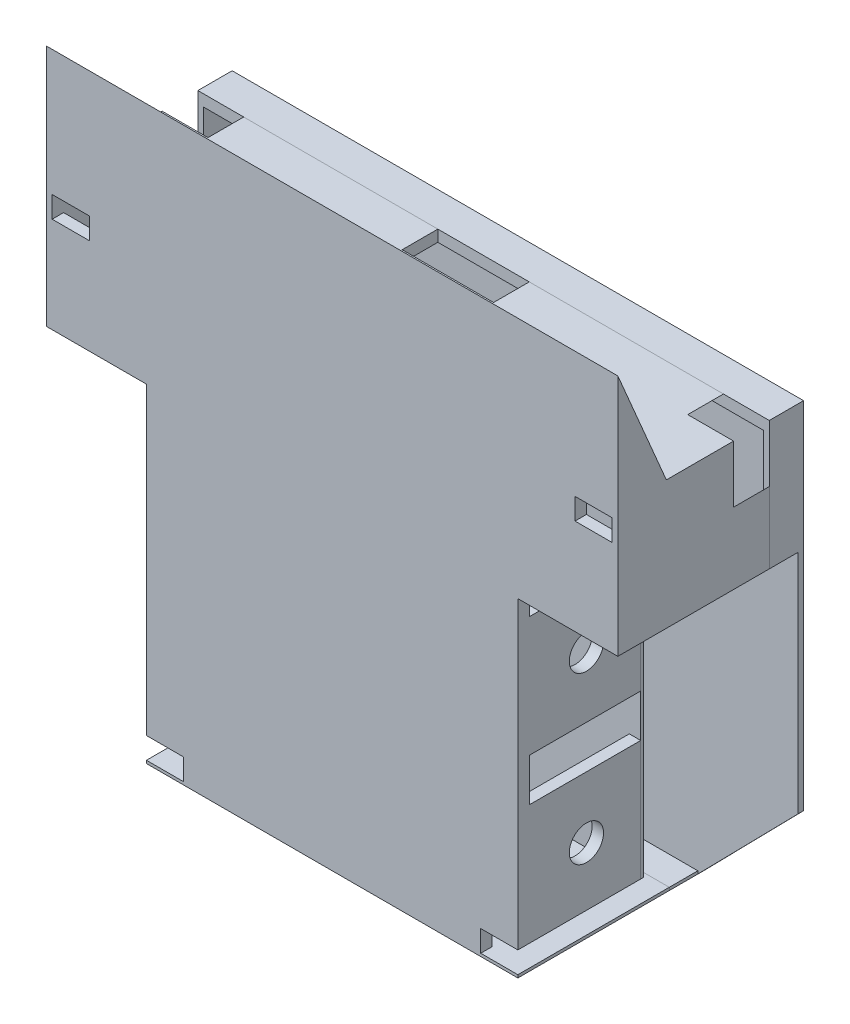
from build123d import *

# Parameters (mm, degrees)
BOSS_EXTRUDE1_DEPTH    = 4
BOSS_EXTRUDE2_DEPTH    = 53
BOSS_EXTRUDE4_DEPTH    = 200
SKETCH5_W              = 25.514718625
SKETCH5_H              = 12.5
CUT_EXTRUDE1_DEPTH     = 20
SKETCH6_W              = 12.5
SKETCH6_H              = 25.514718626
CUT_EXTRUDE2_DEPTH     = 20
BOSS_EXTRUDE5_DEPTH    = 4
SKETCH9_W              = 4
SKETCH9_H              = 99
BOSS_EXTRUDE6_DEPTH    = 39
SKETCH10_W             = 39
SKETCH10_H             = 15
CUT_EXTRUDE5_DEPTH     = 137
SKETCH12_W             = 35
SKETCH12_H             = 53
CUT_EXTRUDE6_DEPTH     = 8
SKETCH13_R             = 6
CUT_EXTRUDE7_DEPTH     = 135
SKETCH15_W             = 129.449663631
SKETCH15_H             = 99
BOSS_EXTRUDE7_DEPTH    = 1
SPLIT1_SURFACE_1_BACK  = 288.766
SPLIT1_SURFACE_1_DEPTH = 577.532
SPLIT1_SURFACE_2_BACK  = 288.766
SPLIT1_SURFACE_2_DEPTH = 577.532
SKETCH17_W             = 13
SKETCH17_H             = 7.5
CUT_EXTRUDE8_DEPTH     = 10
SKETCH21_W             = 130
SKETCH21_H             = 1
BOSS_EXTRUDE10_DEPTH   = 10
SKETCH23_W             = 32
SKETCH23_H             = 12.5
CUT_EXTRUDE9_DEPTH     = 10
BOSS_EXTRUDE14_DEPTH   = 2
SPLIT2_SURFACE_3_BACK  = 291.215
SPLIT2_SURFACE_3_DEPTH = 582.43
SPLIT2_SURFACE_4_BACK  = 291.215
SPLIT2_SURFACE_4_DEPTH = 582.43


with BuildPart() as part:
    # Sketch1 → Boss-Extrude1 (new body)
    with BuildSketch(Plane.XY):
        Polygon((175.95836944, 160), (24.04163056, 160), (0, 135.95836944), (0, 115), (35, 115), (35, 60), (35, 55), (35, 0), (165, 0), (165, 55), (165, 60), (165, 115), (200, 115), (200, 135.95836944), align=None)
    extrude(amount=BOSS_EXTRUDE1_DEPTH)

    # Sketch3 → Boss-Extrude2 (add)
    with BuildSketch(Plane.XY.offset(4)):
        Polygon((0, 0), (200, 0), (200, 1), (199, 1), (1, 1), (0, 1), align=None)
        Polygon((0, 160), (200, 160), (200, 115), (198, 115), (198, 156), (2, 156), (2, 115), (0, 115), align=None)
    extrude(amount=-BOSS_EXTRUDE2_DEPTH)

    # Sketch4 → Boss-Extrude4 (add)
    with BuildSketch(Plane(origin=(200, 0, 0), x_dir=(0, 0, -1), z_dir=(1, 0, 0))):
        Polygon((-4, 160), (-4, 200), (12.978992648, 160), align=None)
    extrude(amount=-BOSS_EXTRUDE4_DEPTH)

    # Sketch5 → Cut-Extrude1 (cut)
    with BuildSketch(Plane(origin=(-67.97918472, 67.97918472, 0), x_dir=(0.7071067811865505, 0.7071067811865447, 0), z_dir=(-0.7071067811865447, 0.7071067811865505, 0))):
        with Locations((111.722871428, 42.75)):
            Rectangle(SKETCH5_W, SKETCH5_H)
    extrude(amount=CUT_EXTRUDE1_DEPTH, mode=Mode.SUBTRACT)

    # Sketch6 → Cut-Extrude2 (cut)
    with BuildSketch(Plane(origin=(167.97918472, 167.97918472, 0), x_dir=(0, 0, -1), z_dir=(0.7071067811865493, 0.7071067811865458, 0))):
        with Locations((42.75, -29.69848481)):
            Rectangle(SKETCH6_W, SKETCH6_H)
    extrude(amount=CUT_EXTRUDE2_DEPTH, mode=Mode.SUBTRACT)

    # Sketch8 → Boss-Extrude5 (add)
    with BuildSketch(Plane.XY.offset(4)):
        Polygon((20.04163056, 156), (2, 156), (2, 137.95836944), align=None)
        Polygon((179.95836944, 156), (198, 156), (198, 137.95836944), align=None)
    extrude(amount=-BOSS_EXTRUDE5_DEPTH)

    # Sketch9 → Boss-Extrude6 (add)
    with BuildSketch(Plane(origin=(0, 0, 0), x_dir=(-1, 0, 0), z_dir=(0, 0, -1))):
        with Locations((-37.550336369, 58)):
            Rectangle(SKETCH9_W, SKETCH9_H)
        with Locations((-163, 58)):
            Rectangle(SKETCH9_W, SKETCH9_H)
    extrude(amount=BOSS_EXTRUDE6_DEPTH)

    # Sketch10 → Cut-Extrude5 (cut)
    with BuildSketch(Plane(origin=(165, 0, 0), x_dir=(0, 0, -1), z_dir=(1, 0, 0))):
        with Locations((19.5, 58)):
            Rectangle(SKETCH10_W, SKETCH10_H)
    extrude(amount=-CUT_EXTRUDE5_DEPTH, mode=Mode.SUBTRACT)

    # Sketch12 → Cut-Extrude6 (cut)
    with BuildSketch(Plane(origin=(0, 1, 0), x_dir=(1, 0, 0), z_dir=(0, 1, 0))):
        with Locations((17.5, 22.5)):
            Rectangle(SKETCH12_W, SKETCH12_H)
        with Locations((182.5, 22.5)):
            Rectangle(SKETCH12_W, SKETCH12_H)
    extrude(amount=-CUT_EXTRUDE6_DEPTH, mode=Mode.SUBTRACT)

    # Sketch13 → Cut-Extrude7 (cut)
    with BuildSketch(Plane(origin=(165, 0, 0), x_dir=(0, 0, -1), z_dir=(1, 0, 0))):
        with Locations((20, 87)):
            Circle(SKETCH13_R)
        with Locations((20, 29)):
            Circle(SKETCH13_R)
    extrude(amount=-CUT_EXTRUDE7_DEPTH, mode=Mode.SUBTRACT)

    # Sketch15 → Boss-Extrude7 (add)
    with BuildSketch(Plane(origin=(0, 0, -39), x_dir=(-1, 0, 0), z_dir=(0, 0, -1))):
        with Locations((-100.275168185, 58)):
            Rectangle(SKETCH15_W, SKETCH15_H)
    extrude(amount=BOSS_EXTRUDE7_DEPTH)


with BuildPart() as body_2:
    # Split1: the piece behind the surface
    add(part.part)
    # Split1 surface: a surface, the sketch's curves swept straight by 577.532 mm
    with BuildLine(Plane(origin=(165, 0, 0), x_dir=(0, 0, -1), z_dir=(1, 0, 0)).offset(-SPLIT1_SURFACE_1_BACK), mode=Mode.PRIVATE) as split1_surface_1_path:
        Line((39, 107.5), (39, 8.5))
    split1_surface_1 = Shell.extrude(split1_surface_1_path.wire(), (1 * SPLIT1_SURFACE_1_DEPTH, 0 * SPLIT1_SURFACE_1_DEPTH, 0 * SPLIT1_SURFACE_1_DEPTH))
    split(bisect_by=split1_surface_1, keep=Keep.BOTTOM)

    # Sketch17 → Cut-Extrude8 (cut)
    with BuildSketch(Plane(origin=(0, 0, 0), x_dir=(-1, 0, 0), z_dir=(0, 0, -1))):
        with Locations((-191.5, 152.25)):
            Rectangle(SKETCH17_W, SKETCH17_H)
        with Locations((-8.5, 152.25)):
            Rectangle(SKETCH17_W, SKETCH17_H)
        with Locations((-158.5, 4.75)):
            Rectangle(SKETCH17_W, SKETCH17_H)
        with Locations((-41.5, 4.75)):
            Rectangle(SKETCH17_W, SKETCH17_H)
    extrude(amount=-CUT_EXTRUDE8_DEPTH, mode=Mode.SUBTRACT)

    # Sketch21 → Boss-Extrude10 (add)
    with BuildSketch(Plane(origin=(0, 0, -49), x_dir=(-1, 0, 0), z_dir=(0, 0, -1))):
        Polygon((-2, 115), (0, 115), (0, 139.95836944), (-2, 137.95836944), align=None)
        Polygon((-2, 137.95836944), (0, 139.95836944), (0, 160), (-200, 160), (-200, 115), (-198, 115), (-198, 156), (-2, 156), align=None)
        with Locations((-100, 0.5)):
            Rectangle(SKETCH21_W, SKETCH21_H)
    extrude(amount=BOSS_EXTRUDE10_DEPTH)

    # Sketch23 → Cut-Extrude9 (cut)
    with BuildSketch(Plane(origin=(0, 160, 0), x_dir=(1, 0, 0), z_dir=(0, 1, 0))):
        with Locations((100, 42.75)):
            Rectangle(SKETCH23_W, SKETCH23_H)
    extrude(amount=-CUT_EXTRUDE9_DEPTH, mode=Mode.SUBTRACT)

    # Sketch22 → Boss-Extrude14 (add)
    with BuildSketch(Plane(origin=(0, 0, -59), x_dir=(-1, 0, 0), z_dir=(0, 0, -1))):
        Polygon((0, 35.707142143), (0, 115), (-2, 115), (-2, 156), (-198, 156), (-198, 115), (-200, 115), (-200, 35.707142143), (-165, 0), (-35, 0), align=None)
        Polygon((-2, 156), (-2, 115), (0, 115), (0, 160), (-200, 160), (-200, 115), (-198, 115), (-198, 156), align=None)
    extrude(amount=BOSS_EXTRUDE14_DEPTH)


with BuildPart() as part_1:
    add(part.part)

    # Split1: split by a surface, the side it looks to stays
    # Split1 surface: a surface, the sketch's curves swept straight by 577.532 mm
    with BuildLine(Plane(origin=(165, 0, 0), x_dir=(0, 0, -1), z_dir=(1, 0, 0)).offset(-SPLIT1_SURFACE_2_BACK), mode=Mode.PRIVATE) as split1_surface_2_path:
        Line((39, 107.5), (39, 8.5))
    split1_surface_2 = Shell.extrude(split1_surface_2_path.wire(), (1 * SPLIT1_SURFACE_2_DEPTH, 0 * SPLIT1_SURFACE_2_DEPTH, 0 * SPLIT1_SURFACE_2_DEPTH))
    split(bisect_by=split1_surface_2, keep=Keep.TOP)


with BuildPart() as body_3:
    # Split2: the piece behind the surface
    add(body_2.part)
    # Split2 surface: a surface, the sketch's curves swept straight by 582.43 mm
    with BuildLine(Plane(origin=(0, 160, 0), x_dir=(1, 0, 0), z_dir=(0, 1, 0)).offset(-SPLIT2_SURFACE_3_BACK), mode=Mode.PRIVATE) as split2_surface_3_path:
        Line((0, 49), (200, 49))
    split2_surface_3 = Shell.extrude(split2_surface_3_path.wire(), (0 * SPLIT2_SURFACE_3_DEPTH, 1 * SPLIT2_SURFACE_3_DEPTH, 0 * SPLIT2_SURFACE_3_DEPTH))
    split(bisect_by=split2_surface_3, keep=Keep.BOTTOM)


with BuildPart() as body_2_1:
    add(body_2.part)

    # Split2: split by a surface, the side it looks to stays
    # Split2 surface: a surface, the sketch's curves swept straight by 582.43 mm
    with BuildLine(Plane(origin=(0, 160, 0), x_dir=(1, 0, 0), z_dir=(0, 1, 0)).offset(-SPLIT2_SURFACE_4_BACK), mode=Mode.PRIVATE) as split2_surface_4_path:
        Line((0, 49), (200, 49))
    split2_surface_4 = Shell.extrude(split2_surface_4_path.wire(), (0 * SPLIT2_SURFACE_4_DEPTH, 1 * SPLIT2_SURFACE_4_DEPTH, 0 * SPLIT2_SURFACE_4_DEPTH))
    split(bisect_by=split2_surface_4, keep=Keep.TOP)


solid = Compound([part_1.part, body_3.part, body_2_1.part])
